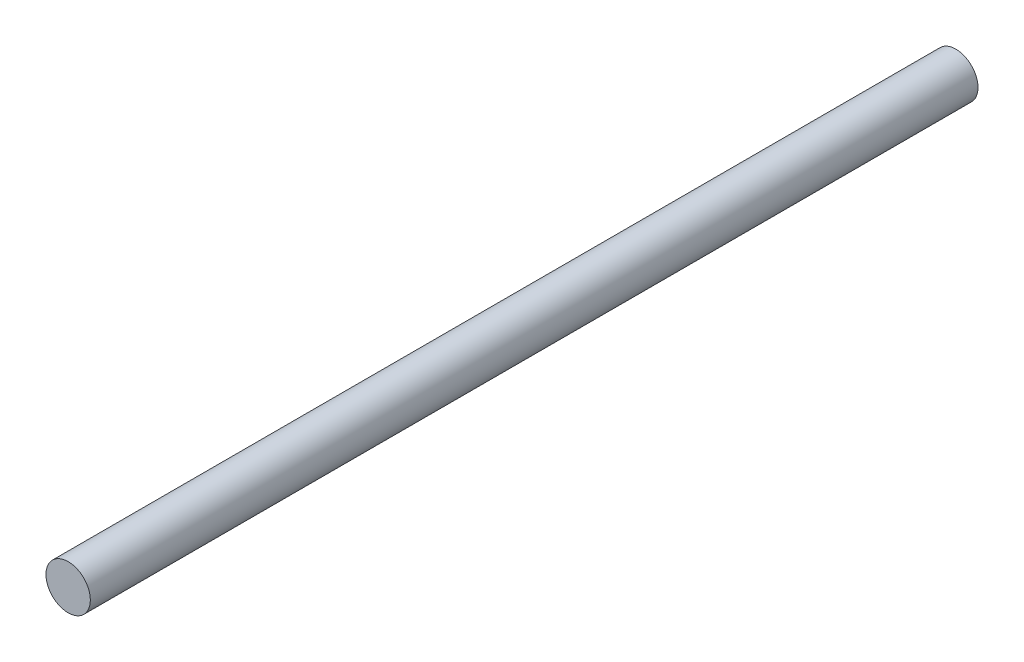
from build123d import *

# Parameters (mm, degrees)
SKETCH1_R           = 4.5
BOSS_EXTRUDE1_DEPTH = 180


with BuildPart() as part:
    # Sketch1 → Boss-Extrude1 (new body)
    with BuildSketch(Plane.XY):
        Circle(SKETCH1_R)
    extrude(amount=BOSS_EXTRUDE1_DEPTH)


solid = part.part
